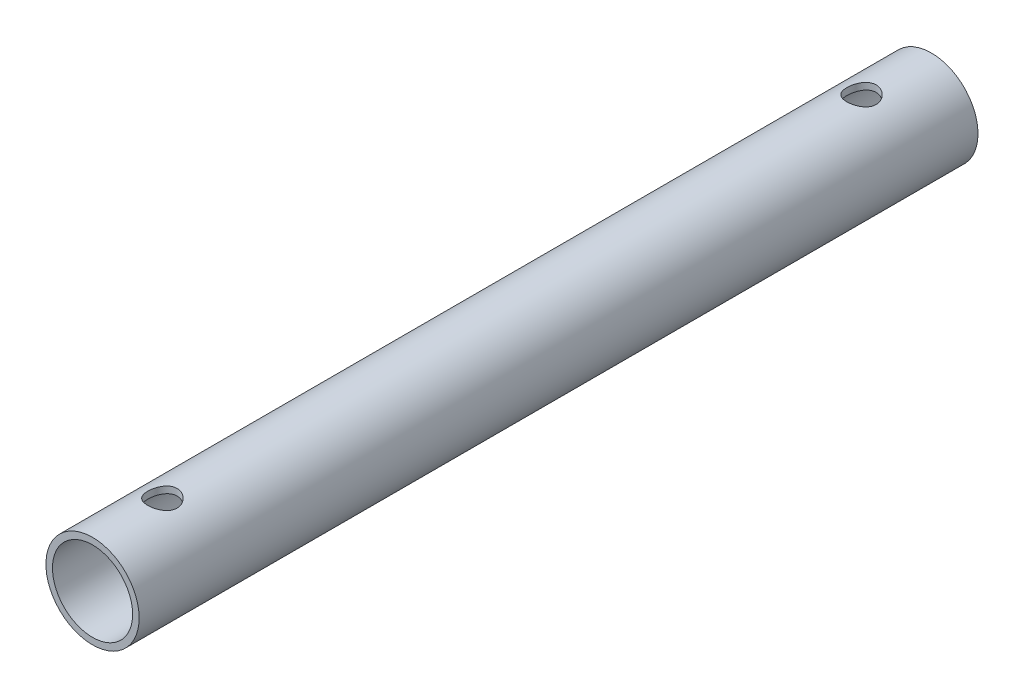
from build123d import *

# Parameters (mm, degrees)
SKETCH1_R               = 6.35
SKETCH1_R_2             = 5.461
EXTRUDE1_DEPTH          = 114.3
SKETCH2_R               = 2
CUT_EXTRUDE1_DEPTH      = 38.1
CUT_EXTRUDE1_DEPTH_BACK = 38.1


with BuildPart() as part:
    # Sketch1 → Extrude1 (new body)
    with BuildSketch(Plane.XY):
        Circle(SKETCH1_R)
        Circle(SKETCH1_R_2, mode=Mode.SUBTRACT)
    extrude(amount=EXTRUDE1_DEPTH)

    # Sketch2 → Cut-Extrude1 (cut, two sides)
    with BuildSketch(Plane(origin=(0, 0, 0), x_dir=(1, 0, 0), z_dir=(0, 1, 0))) as cut_extrude1_sk:
        with Locations(Location((0, -9.525, 0), (0, 0, 270))):  # turned: the seam where the file's is
            Circle(SKETCH2_R)
        with Locations(Location((0, -104.775, 0), (0, 0, 270))):  # turned: the seam where the file's is
            Circle(SKETCH2_R)
    extrude(amount=CUT_EXTRUDE1_DEPTH, mode=Mode.SUBTRACT)
    extrude(cut_extrude1_sk.sketch, amount=-CUT_EXTRUDE1_DEPTH_BACK, mode=Mode.SUBTRACT)


solid = part.part
